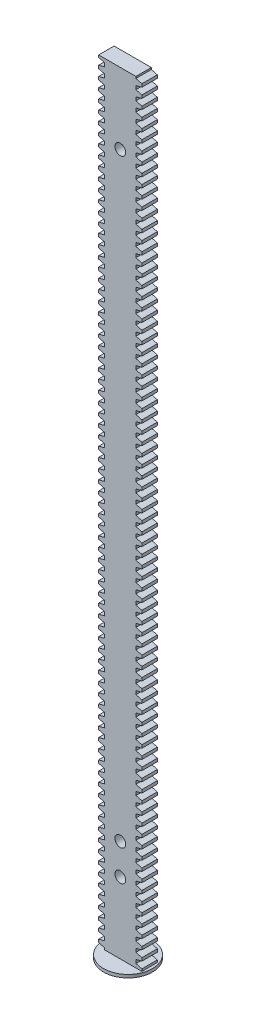
from build123d import *

# Parameters (mm, degrees)
EXTRUDE_1_DEPTH     = 5
SKETCH_2_R          = 1.75
CUT_EXTRUDE_1_DEPTH = 5
SKETCH_4_R          = 7.905
EXTRUDE_3_DEPTH     = 1


with BuildPart() as part:
    # 草图1 → 凸台-拉伸1 (new body)
    with BuildSketch(Plane.XY):
        Polygon((-85.955191959, 233.569921221), (-75.955191959, 233.569921221), (-75.902391959, 233.569921221), (-75.902391959, 232.993795039), (-73.955191959, 232.490214879), (-73.955191959, 231.508034913), (-75.902391959, 231.004454753), (-75.902391959, 229.852202389), (-73.955191959, 229.348622229), (-73.955191959, 228.366442263), (-75.902391959, 227.862862103), (-75.902391959, 226.710609739), (-73.955191959, 226.207029579), (-73.955191959, 225.224849613), (-75.902391959, 224.721269453), (-75.902391959, 223.569017089), (-73.955191959, 223.065436929), (-73.955191959, 222.083256963), (-75.902391959, 221.579676803), (-75.902391959, 220.427424439), (-73.955191959, 219.923844279), (-73.955191959, 218.941664313), (-75.902391959, 218.438084153), (-75.902391959, 217.285831789), (-73.955191959, 216.782251629), (-73.955191959, 215.800071663), (-75.902391959, 215.296491503), (-75.902391959, 214.144239139), (-73.955191959, 213.640658979), (-73.955191959, 212.658479013), (-75.902391959, 212.154898853), (-75.902391959, 211.002646489), (-73.955191959, 210.499066329), (-73.955191959, 209.516886363), (-75.902391959, 209.013306203), (-75.902391959, 207.861053839), (-73.955191959, 207.357473679), (-73.955191959, 206.375293713), (-75.902391959, 205.871713553), (-75.902391959, 204.719461189), (-73.955191959, 204.215881029), (-73.955191959, 203.233701063), (-75.902391959, 202.730120903), (-75.902391959, 201.577868539), (-73.955191959, 201.074288379), (-73.955191959, 200.092108413), (-75.902391959, 199.588528253), (-75.902391959, 198.436275889), (-73.955191959, 197.932695729), (-73.955191959, 196.950515763), (-75.902391959, 196.446935603), (-75.902391959, 195.294683239), (-73.955191959, 194.791103079), (-73.955191959, 193.808923113), (-75.902391959, 193.305342953), (-75.902391959, 192.153090589), (-73.955191959, 191.649510429), (-73.955191959, 190.667330463), (-75.902391959, 190.163750303), (-75.902391959, 189.011497939), (-73.955191959, 188.507917779), (-73.955191959, 187.525737813), (-75.902391959, 187.022157653), (-75.902391959, 185.869905289), (-73.955191959, 185.366325129), (-73.955191959, 184.384145163), (-75.902391959, 183.880565003), (-75.902391959, 182.728312639), (-73.955191959, 182.224732479), (-73.955191959, 181.242552513), (-75.902391959, 180.738972353), (-75.902391959, 179.586719989), (-73.955191959, 179.083139829), (-73.955191959, 178.100959863), (-75.902391959, 177.597379703), (-75.902391959, 176.445127339), (-73.955191959, 175.941547179), (-73.955191959, 174.959367213), (-75.902391959, 174.455787053), (-75.902391959, 173.303534689), (-73.955191959, 172.799954529), (-73.955191959, 171.817774563), (-75.902391959, 171.314194403), (-75.902391959, 170.161942039), (-73.955191959, 169.658361879), (-73.955191959, 168.676181913), (-75.902391959, 168.172601753), (-75.902391959, 167.020349389), (-73.955191959, 166.516769229), (-73.955191959, 165.534589263), (-75.902391959, 165.031009103), (-75.902391959, 163.878756739), (-73.955191959, 163.375176579), (-73.955191959, 162.392996613), (-75.902391959, 161.889416453), (-75.902391959, 160.737164089), (-73.955191959, 160.233583929), (-73.955191959, 159.251403963), (-75.902391959, 158.747823803), (-75.902391959, 157.595571439), (-73.955191959, 157.091991279), (-73.955191959, 156.109811313), (-75.902391959, 155.606231153), (-75.902391959, 154.453978789), (-73.955191959, 153.950398629), (-73.955191959, 152.968218663), (-75.902391959, 152.464638503), (-75.902391959, 151.312386139), (-73.955191959, 150.808805979), (-73.955191959, 149.826626013), (-75.902391959, 149.323045853), (-75.902391959, 148.170793489), (-73.955191959, 147.667213329), (-73.955191959, 146.685033363), (-75.902391959, 146.181453203), (-75.902391959, 145.029200839), (-73.955191959, 144.525620679), (-73.955191959, 143.543440713), (-75.902391959, 143.039860553), (-75.902391959, 141.887608189), (-73.955191959, 141.384028029), (-73.955191959, 140.401848063), (-75.902391959, 139.898267903), (-75.902391959, 138.746015539), (-73.955191959, 138.242435379), (-73.955191959, 137.260255413), (-75.902391959, 136.756675253), (-75.902391959, 135.604422889), (-73.955191959, 135.100842729), (-73.955191959, 134.118662763), (-75.902391959, 133.615082603), (-75.902391959, 132.462830239), (-73.955191959, 131.959250079), (-73.955191959, 130.977070113), (-75.902391959, 130.473489953), (-75.902391959, 129.321237589), (-73.955191959, 128.817657429), (-73.955191959, 127.835477463), (-75.902391959, 127.331897303), (-75.902391959, 126.179644939), (-73.955191959, 125.676064779), (-73.955191959, 124.693884813), (-75.902391959, 124.190304653), (-75.902391959, 123.038052289), (-73.955191959, 122.534472129), (-73.955191959, 121.552292163), (-75.902391959, 121.048712003), (-75.902391959, 119.896459639), (-73.955191959, 119.392879479), (-73.955191959, 118.410699513), (-75.902391959, 117.907119353), (-75.902391959, 116.754866989), (-73.955191959, 116.251286829), (-73.955191959, 115.269106863), (-75.902391959, 114.765526703), (-75.902391959, 113.613274339), (-73.955191959, 113.109694179), (-73.955191959, 112.127514213), (-75.902391959, 111.623934053), (-75.902391959, 110.471681689), (-73.955191959, 109.968101529), (-73.955191959, 108.985921563), (-75.902391959, 108.482341403), (-75.902391959, 107.330089039), (-73.955191959, 106.826508879), (-73.955191959, 105.844328913), (-75.902391959, 105.340748753), (-75.902391959, 104.188496389), (-73.955191959, 103.684916229), (-73.955191959, 102.702736263), (-75.902391959, 102.199156103), (-75.902391959, 101.046903739), (-73.955191959, 100.543323579), (-73.955191959, 99.561143613), (-75.902391959, 99.057563453), (-75.902391959, 97.905311089), (-73.955191959, 97.401730929), (-73.955191959, 96.419550963), (-75.902391959, 95.915970803), (-75.902391959, 94.763718439), (-73.955191959, 94.260138279), (-73.955191959, 93.277958313), (-75.902391959, 92.774378153), (-75.902391959, 91.622125789), (-73.955191959, 91.118545629), (-73.955191959, 90.136365663), (-75.902391959, 89.632785503), (-75.902391959, 88.480533139), (-73.955191959, 87.976952979), (-73.955191959, 86.994773013), (-75.902391959, 86.491192853), (-75.902391959, 85.338940489), (-73.955191959, 84.835360329), (-73.955191959, 83.853180363), (-75.902391959, 83.349600203), (-75.902391959, 82.197347839), (-73.955191959, 81.693767679), (-73.955191959, 80.711587713), (-75.902391959, 80.208007553), (-75.902391959, 79.055755189), (-73.955191959, 78.552175029), (-73.955191959, 77.569995063), (-75.902391959, 77.066414903), (-75.902391959, 75.914162539), (-73.955191959, 75.410582379), (-73.955191959, 74.428402413), (-75.902391959, 73.924822253), (-75.902391959, 72.772569889), (-73.955191959, 72.268989729), (-73.955191959, 71.286809763), (-75.902391959, 70.783229603), (-75.902391959, 69.630977239), (-73.955191959, 69.127397079), (-73.955191959, 68.145217113), (-75.902391959, 67.641636953), (-75.902391959, 66.489384589), (-73.955191959, 65.985804429), (-73.955191959, 65.003624463), (-75.902391959, 64.500044303), (-75.902391959, 63.347791939), (-73.955191959, 62.844211779), (-73.955191959, 61.862031813), (-75.902391959, 61.358451653), (-75.902391959, 60.206199289), (-73.955191959, 59.702619129), (-73.955191959, 58.720439163), (-75.902391959, 58.216859003), (-75.902391959, 57.064606639), (-73.955191959, 56.561026479), (-73.955191959, 55.578846513), (-75.902391959, 55.075266353), (-75.902391959, 53.923013989), (-73.955191959, 53.419433829), (-73.955191959, 52.437253863), (-75.902391959, 51.933673703), (-75.902391959, 50.781421339), (-73.955191959, 50.277841179), (-73.955191959, 49.295661213), (-75.902391959, 48.792081053), (-75.902391959, 47.639828689), (-73.955191959, 47.136248529), (-73.955191959, 46.154068563), (-75.902391959, 45.650488403), (-75.902391959, 44.498236039), (-73.955191959, 43.994655879), (-73.955191959, 43.012475913), (-75.902391959, 42.508895753), (-75.902391959, 41.356643389), (-73.955191959, 40.853063229), (-73.955191959, 39.870883263), (-75.902391959, 39.367303103), (-75.902391959, 38.215050739), (-73.955191959, 37.711470579), (-73.955191959, 36.729290613), (-75.902391959, 36.225710453), (-75.902391959, 35.073458089), (-73.955191959, 34.569877929), (-73.955191959, 33.587697963), (-75.902391959, 33.084117803), (-75.902391959, 31.931865439), (-73.955191959, 31.428285279), (-73.955191959, 30.446105313), (-75.902391959, 29.942525153), (-75.902391959, 28.790272789), (-73.955191959, 28.286692629), (-73.955191959, 27.304512663), (-75.902391959, 26.800932503), (-75.902391959, 25.648680139), (-73.955191959, 25.145099979), (-73.955191959, 24.162920013), (-75.902391959, 23.659339853), (-75.902391959, 22.507087489), (-73.955191959, 22.003507329), (-73.955191959, 21.021327363), (-75.902391959, 20.517747203), (-75.902391959, 19.365494839), (-73.955191959, 18.861914679), (-73.955191959, 17.879734713), (-75.902391959, 17.376154553), (-75.902391959, 16.223902189), (-73.955191959, 15.720322029), (-73.955191959, 14.738142063), (-75.902391959, 14.234561903), (-75.902391959, 13.082309539), (-73.955191959, 12.578729379), (-73.955191959, 11.596549413), (-75.902391959, 11.092969253), (-75.902391959, 9.940716889), (-73.955191959, 9.437136729), (-73.955191959, 8.454956763), (-75.902391959, 7.951376603), (-75.902391959, 6.799124239), (-73.955191959, 6.295544079), (-73.955191959, 5.313364113), (-75.902391959, 4.809783953), (-75.902391959, 3.657531589), (-73.955191959, 3.153951429), (-73.955191959, 2.171771463), (-75.902391959, 1.668191303), (-75.902391959, 0.515938939), (-73.955191959, 0.012358779), (-73.955191959, -0.969821187), (-75.902391959, -1.473401347), (-75.902391959, -2.625653711), (-73.955191959, -3.129233871), (-73.955191959, -4.111413837), (-75.902391959, -4.614993997), (-75.902391959, -5.767246361), (-73.955191959, -6.270826521), (-73.955191959, -7.253006487), (-75.902391959, -7.756586647), (-75.902391959, -8.908839011), (-73.955191959, -9.412419171), (-73.955191959, -10.394599137), (-75.902391959, -10.898179297), (-75.902391959, -12.050431661), (-73.955191959, -12.554011821), (-73.955191959, -13.536191787), (-75.902391959, -14.039771947), (-75.902391959, -15.192024311), (-73.955191959, -15.695604471), (-73.955191959, -16.430078779), (-75.955191959, -16.430078779), (-86.007991959, -16.430078779), (-86.007991959, -15.853952597), (-87.955191959, -15.350372437), (-87.955191959, -14.368192471), (-86.007991959, -13.864612311), (-86.007991959, -12.712359947), (-87.955191959, -12.208779787), (-87.955191959, -11.226599821), (-86.007991959, -10.723019661), (-86.007991959, -9.570767297), (-87.955191959, -9.067187137), (-87.955191959, -8.085007171), (-86.007991959, -7.581427011), (-86.007991959, -6.429174647), (-87.955191959, -5.925594487), (-87.955191959, -4.943414521), (-86.007991959, -4.439834361), (-86.007991959, -3.287581997), (-87.955191959, -2.784001837), (-87.955191959, -1.801821871), (-86.007991959, -1.298241711), (-86.007991959, -0.145989347), (-87.955191959, 0.357590813), (-87.955191959, 1.339770779), (-86.007991959, 1.843350939), (-86.007991959, 2.995603303), (-87.955191959, 3.499183463), (-87.955191959, 4.481363429), (-86.007991959, 4.984943589), (-86.007991959, 6.137195953), (-87.955191959, 6.640776113), (-87.955191959, 7.622956079), (-86.007991959, 8.126536239), (-86.007991959, 9.278788603), (-87.955191959, 9.782368763), (-87.955191959, 10.764548729), (-86.007991959, 11.268128889), (-86.007991959, 12.420381253), (-87.955191959, 12.923961413), (-87.955191959, 13.906141379), (-86.007991959, 14.409721539), (-86.007991959, 15.561973903), (-87.955191959, 16.065554063), (-87.955191959, 17.047734029), (-86.007991959, 17.551314189), (-86.007991959, 18.703566553), (-87.955191959, 19.207146713), (-87.955191959, 20.189326679), (-86.007991959, 20.692906839), (-86.007991959, 21.845159203), (-87.955191959, 22.348739363), (-87.955191959, 23.330919329), (-86.007991959, 23.834499489), (-86.007991959, 24.986751853), (-87.955191959, 25.490332013), (-87.955191959, 26.472511979), (-86.007991959, 26.976092139), (-86.007991959, 28.128344503), (-87.955191959, 28.631924663), (-87.955191959, 29.614104629), (-86.007991959, 30.117684789), (-86.007991959, 31.269937153), (-87.955191959, 31.773517313), (-87.955191959, 32.755697279), (-86.007991959, 33.259277439), (-86.007991959, 34.411529803), (-87.955191959, 34.915109963), (-87.955191959, 35.897289929), (-86.007991959, 36.400870089), (-86.007991959, 37.553122453), (-87.955191959, 38.056702613), (-87.955191959, 39.038882579), (-86.007991959, 39.542462739), (-86.007991959, 40.694715103), (-87.955191959, 41.198295263), (-87.955191959, 42.180475229), (-86.007991959, 42.684055389), (-86.007991959, 43.836307753), (-87.955191959, 44.339887913), (-87.955191959, 45.322067879), (-86.007991959, 45.825648039), (-86.007991959, 46.977900403), (-87.955191959, 47.481480563), (-87.955191959, 48.463660529), (-86.007991959, 48.967240689), (-86.007991959, 50.119493053), (-87.955191959, 50.623073213), (-87.955191959, 51.605253179), (-86.007991959, 52.108833339), (-86.007991959, 53.261085703), (-87.955191959, 53.764665863), (-87.955191959, 54.746845829), (-86.007991959, 55.250425989), (-86.007991959, 56.402678353), (-87.955191959, 56.906258513), (-87.955191959, 57.888438479), (-86.007991959, 58.392018639), (-86.007991959, 59.544271003), (-87.955191959, 60.047851163), (-87.955191959, 61.030031129), (-86.007991959, 61.533611289), (-86.007991959, 62.685863653), (-87.955191959, 63.189443813), (-87.955191959, 64.171623779), (-86.007991959, 64.675203939), (-86.007991959, 65.827456303), (-87.955191959, 66.331036463), (-87.955191959, 67.313216429), (-86.007991959, 67.816796589), (-86.007991959, 68.969048953), (-87.955191959, 69.472629113), (-87.955191959, 70.454809079), (-86.007991959, 70.958389239), (-86.007991959, 72.110641603), (-87.955191959, 72.614221763), (-87.955191959, 73.596401729), (-86.007991959, 74.099981889), (-86.007991959, 75.252234253), (-87.955191959, 75.755814413), (-87.955191959, 76.737994379), (-86.007991959, 77.241574539), (-86.007991959, 78.393826903), (-87.955191959, 78.897407063), (-87.955191959, 79.879587029), (-86.007991959, 80.383167189), (-86.007991959, 81.535419553), (-87.955191959, 82.038999713), (-87.955191959, 83.021179679), (-86.007991959, 83.524759839), (-86.007991959, 84.677012203), (-87.955191959, 85.180592363), (-87.955191959, 86.162772329), (-86.007991959, 86.666352489), (-86.007991959, 87.818604853), (-87.955191959, 88.322185013), (-87.955191959, 89.304364979), (-86.007991959, 89.807945139), (-86.007991959, 90.960197503), (-87.955191959, 91.463777663), (-87.955191959, 92.445957629), (-86.007991959, 92.949537789), (-86.007991959, 94.101790153), (-87.955191959, 94.605370313), (-87.955191959, 95.587550279), (-86.007991959, 96.091130439), (-86.007991959, 97.243382803), (-87.955191959, 97.746962963), (-87.955191959, 98.729142929), (-86.007991959, 99.232723089), (-86.007991959, 100.384975453), (-87.955191959, 100.888555613), (-87.955191959, 101.870735579), (-86.007991959, 102.374315739), (-86.007991959, 103.526568103), (-87.955191959, 104.030148263), (-87.955191959, 105.012328229), (-86.007991959, 105.515908389), (-86.007991959, 106.668160753), (-87.955191959, 107.171740913), (-87.955191959, 108.153920879), (-86.007991959, 108.657501039), (-86.007991959, 109.809753403), (-87.955191959, 110.313333563), (-87.955191959, 111.295513529), (-86.007991959, 111.799093689), (-86.007991959, 112.951346053), (-87.955191959, 113.454926213), (-87.955191959, 114.437106179), (-86.007991959, 114.940686339), (-86.007991959, 116.092938703), (-87.955191959, 116.596518863), (-87.955191959, 117.578698829), (-86.007991959, 118.082278989), (-86.007991959, 119.234531353), (-87.955191959, 119.738111513), (-87.955191959, 120.720291479), (-86.007991959, 121.223871639), (-86.007991959, 122.376124003), (-87.955191959, 122.879704163), (-87.955191959, 123.861884129), (-86.007991959, 124.365464289), (-86.007991959, 125.517716653), (-87.955191959, 126.021296813), (-87.955191959, 127.003476779), (-86.007991959, 127.507056939), (-86.007991959, 128.659309303), (-87.955191959, 129.162889463), (-87.955191959, 130.145069429), (-86.007991959, 130.648649589), (-86.007991959, 131.800901953), (-87.955191959, 132.304482113), (-87.955191959, 133.286662079), (-86.007991959, 133.790242239), (-86.007991959, 134.942494603), (-87.955191959, 135.446074763), (-87.955191959, 136.428254729), (-86.007991959, 136.931834889), (-86.007991959, 138.084087253), (-87.955191959, 138.587667413), (-87.955191959, 139.569847379), (-86.007991959, 140.073427539), (-86.007991959, 141.225679903), (-87.955191959, 141.729260063), (-87.955191959, 142.711440029), (-86.007991959, 143.215020189), (-86.007991959, 144.367272553), (-87.955191959, 144.870852713), (-87.955191959, 145.853032679), (-86.007991959, 146.356612839), (-86.007991959, 147.508865203), (-87.955191959, 148.012445363), (-87.955191959, 148.994625329), (-86.007991959, 149.498205489), (-86.007991959, 150.650457853), (-87.955191959, 151.154038013), (-87.955191959, 152.136217979), (-86.007991959, 152.639798139), (-86.007991959, 153.792050503), (-87.955191959, 154.295630663), (-87.955191959, 155.277810629), (-86.007991959, 155.781390789), (-86.007991959, 156.933643153), (-87.955191959, 157.437223313), (-87.955191959, 158.419403279), (-86.007991959, 158.922983439), (-86.007991959, 160.075235803), (-87.955191959, 160.578815963), (-87.955191959, 161.560995929), (-86.007991959, 162.064576089), (-86.007991959, 163.216828453), (-87.955191959, 163.720408613), (-87.955191959, 164.702588579), (-86.007991959, 165.206168739), (-86.007991959, 166.358421103), (-87.955191959, 166.862001263), (-87.955191959, 167.844181229), (-86.007991959, 168.347761389), (-86.007991959, 169.500013753), (-87.955191959, 170.003593913), (-87.955191959, 170.985773879), (-86.007991959, 171.489354039), (-86.007991959, 172.641606403), (-87.955191959, 173.145186563), (-87.955191959, 174.127366529), (-86.007991959, 174.630946689), (-86.007991959, 175.783199053), (-87.955191959, 176.286779213), (-87.955191959, 177.268959179), (-86.007991959, 177.772539339), (-86.007991959, 178.924791703), (-87.955191959, 179.428371863), (-87.955191959, 180.410551829), (-86.007991959, 180.914131989), (-86.007991959, 182.066384353), (-87.955191959, 182.569964513), (-87.955191959, 183.552144479), (-86.007991959, 184.055724639), (-86.007991959, 185.207977003), (-87.955191959, 185.711557163), (-87.955191959, 186.693737129), (-86.007991959, 187.197317289), (-86.007991959, 188.349569653), (-87.955191959, 188.853149813), (-87.955191959, 189.835329779), (-86.007991959, 190.338909939), (-86.007991959, 191.491162303), (-87.955191959, 191.994742463), (-87.955191959, 192.976922429), (-86.007991959, 193.480502589), (-86.007991959, 194.632754953), (-87.955191959, 195.136335113), (-87.955191959, 196.118515079), (-86.007991959, 196.622095239), (-86.007991959, 197.774347603), (-87.955191959, 198.277927763), (-87.955191959, 199.260107729), (-86.007991959, 199.763687889), (-86.007991959, 200.915940253), (-87.955191959, 201.419520413), (-87.955191959, 202.401700379), (-86.007991959, 202.905280539), (-86.007991959, 204.057532903), (-87.955191959, 204.561113063), (-87.955191959, 205.543293029), (-86.007991959, 206.046873189), (-86.007991959, 207.199125553), (-87.955191959, 207.702705713), (-87.955191959, 208.684885679), (-86.007991959, 209.188465839), (-86.007991959, 210.340718203), (-87.955191959, 210.844298363), (-87.955191959, 211.826478329), (-86.007991959, 212.330058489), (-86.007991959, 213.482310853), (-87.955191959, 213.985891013), (-87.955191959, 214.968070979), (-86.007991959, 215.471651139), (-86.007991959, 216.623903503), (-87.955191959, 217.127483663), (-87.955191959, 218.109663629), (-86.007991959, 218.613243789), (-86.007991959, 219.765496153), (-87.955191959, 220.269076313), (-87.955191959, 221.251256279), (-86.007991959, 221.754836439), (-86.007991959, 222.907088803), (-87.955191959, 223.410668963), (-87.955191959, 224.392848929), (-86.007991959, 224.896429089), (-86.007991959, 226.048681453), (-87.955191959, 226.552261613), (-87.955191959, 227.534441579), (-86.007991959, 228.038021739), (-86.007991959, 229.190274103), (-87.955191959, 229.693854263), (-87.955191959, 230.676034229), (-86.007991959, 231.179614389), (-86.007991959, 232.331866753), (-87.955191959, 232.835446913), (-87.955191959, 233.569921221), align=None)
    extrude(amount=EXTRUDE_1_DEPTH)

    # 草图2 → 切除-拉伸1 (cut)
    with BuildSketch(Plane.XY.offset(5)):
        with Locations((-80.955191959, 6.569921221)):
            Circle(SKETCH_2_R)
        with Locations((-80.955191959, 16.569921221)):
            Circle(SKETCH_2_R)
        with Locations((-80.955191959, 210.569921221)):
            Circle(SKETCH_2_R)
    extrude(amount=-CUT_EXTRUDE_1_DEPTH, mode=Mode.SUBTRACT)

    # 草图4 → 凸台-拉伸3 (add)
    with BuildSketch(Plane.XZ.offset(16.430078779)):
        with Locations((-80.955191959, 2.5)):
            Circle(SKETCH_4_R)
    extrude(amount=EXTRUDE_3_DEPTH)


solid = part.part
